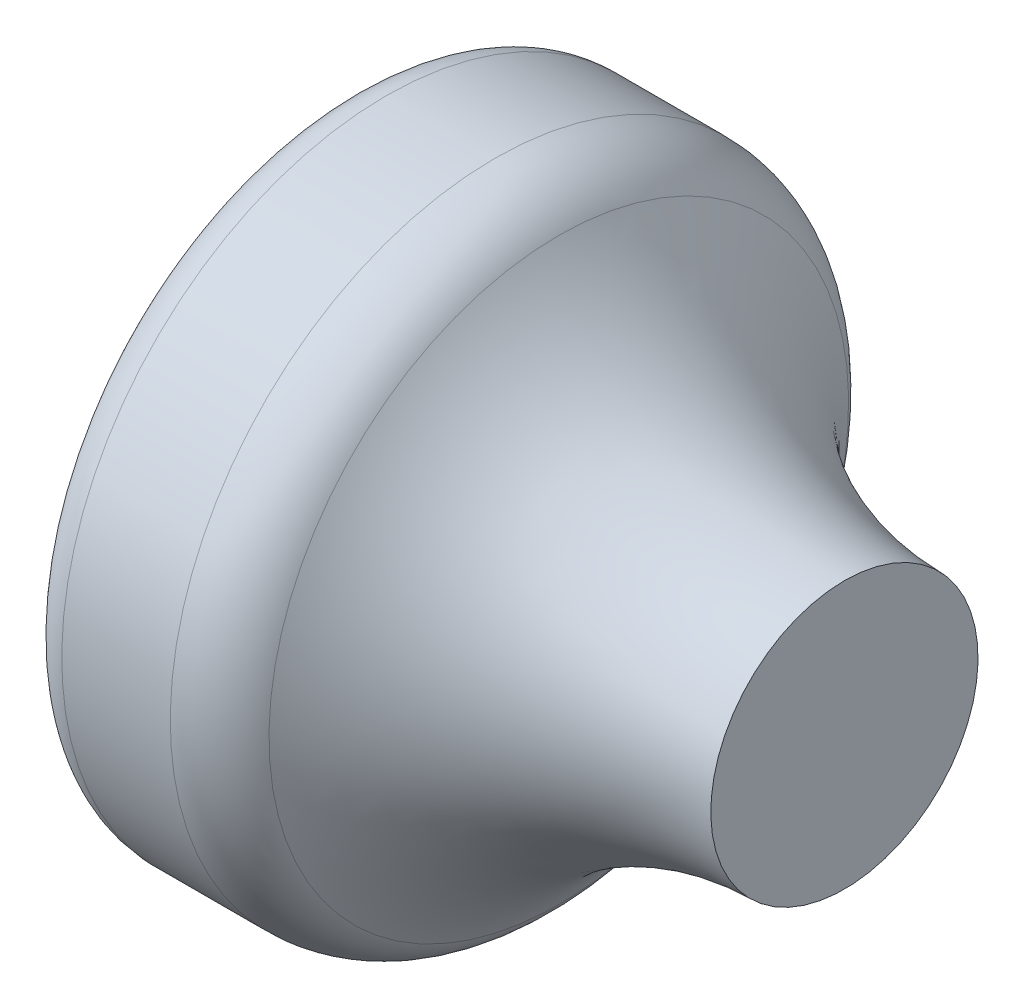
from build123d import *


with BuildPart() as part:
    # Sketch1 → Revolve1 (revolve)
    with BuildSketch(Plane.XY):
        with BuildLine():
            Line((-13, 0), (-13, 7.5))
            ThreePointArc((-13, 7.5), (-12.707106781, 8.207106781), (-12, 8.5))
            Line((-12, 8.5), (-9.157320126, 8.5))
            ThreePointArc((-9.157320126, 8.5), (-8.203836935, 8.258086973), (-7.481013749, 7.590869804))
            ThreePointArc((-7.481013749, 7.590869804), (-4.255694574, 4.603306101), (0, 3.5))
            Line((0, 3.5), (0, 0))
            Line((0, 0), (-13, 0))
        make_face()
    revolve(axis=Axis((0, 0, 0), (-1, 0, 0)))


solid = part.part
